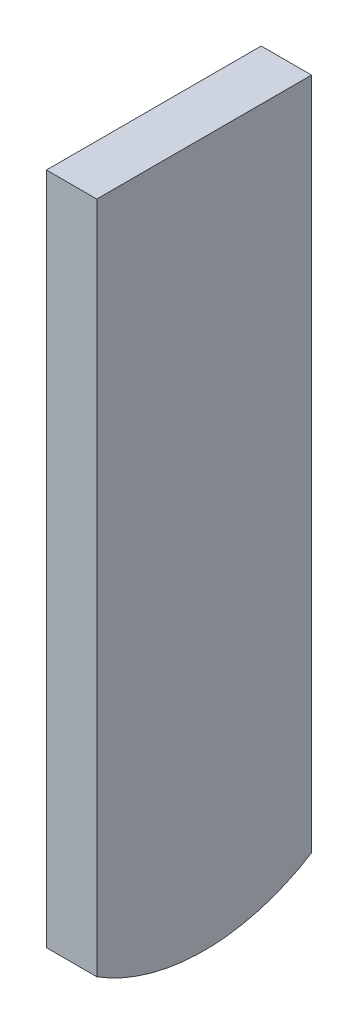
from build123d import *

# Parameters (mm, degrees)
SPIN_W           = 1.5
SPIN_H           = 6.4
FPIN_DEPTH       = 21
FPIN2_DEPTH      = 1.75
FPIN2_DEPTH_BACK = 1.75


with BuildPart() as part:
    # SPin → FPin (new body)
    with BuildSketch(Plane(origin=(0, 0, 0), x_dir=(1, 0, 0), z_dir=(0, 1, 0))):
        Rectangle(SPIN_W, SPIN_H)
    extrude(amount=-FPIN_DEPTH)

    # SPin2 → FPin2 (cut, two sides)
    with BuildSketch(Plane(origin=(0, 0, 0), x_dir=(0, 0, -1), z_dir=(1, 0, 0))) as fpin2_sk:
        with BuildLine():
            Line((-47.307022322, 7.733531608), (-3.2, -20.075431016))
            ThreePointArc((-3.2, -20.075431016), (0, -21), (3.2, -20.075431016))
            Line((3.2, -20.075431016), (47.307022322, 7.733531608))
            Line((47.307022322, 7.733531608), (47.307022322, -96.550078233))
            Line((47.307022322, -96.550078233), (-47.307022322, -96.550078233))
            Line((-47.307022322, -96.550078233), (-47.307022322, 7.733531608))
        make_face()
    extrude(amount=FPIN2_DEPTH, mode=Mode.SUBTRACT)
    extrude(fpin2_sk.sketch, amount=-FPIN2_DEPTH_BACK, mode=Mode.SUBTRACT)


solid = part.part
